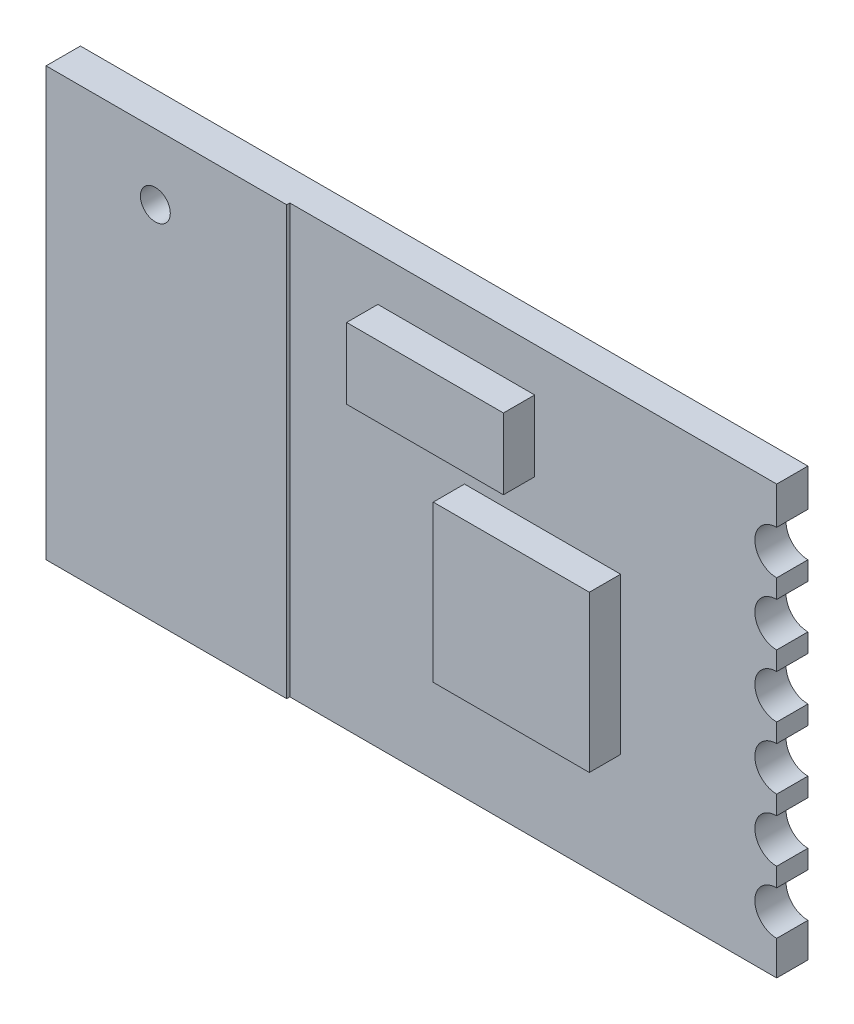
from build123d import *

# Parameters (mm, degrees)
BOSS_EXTRUDE1_DEPTH = 1
SKETCH2_W           = 7.706049631
SKETCH2_H           = 13.7
BOSS_EXTRUDE2_DEPTH = 0.1
SKETCH3_R           = 0.478791287
CUT_EXTRUDE1_DEPTH  = 2.1
SKETCH4_W           = 5
SKETCH4_H           = 5
BOSS_EXTRUDE3_DEPTH = 1
SKETCH6_W           = 5.021657736
SKETCH6_H           = 2.270064456
BOSS_EXTRUDE5_DEPTH = 1


with BuildPart() as part:
    # Sketch1 → Boss-Extrude1 (new body)
    with BuildSketch(Plane.XY):
        with BuildLine():
            Line((13.817814776, 5.306721311), (13.817814776, 4.706721311))
            ThreePointArc((13.817814776, 4.706721311), (13.117814776, 4.006721311), (13.817814776, 3.306721311))
            Line((13.817814776, 3.306721311), (13.817814776, 2.706721311))
            ThreePointArc((13.817814776, 2.706721311), (13.117814776, 2.006721311), (13.817814776, 1.306721311))
            Line((13.817814776, 1.306721311), (13.817814776, 0.706721311))
            ThreePointArc((13.817814776, 0.706721311), (13.117814776, 0.006721311), (13.817814776, -0.693278689))
            Line((13.817814776, -0.693278689), (13.817814776, -1.293278689))
            ThreePointArc((13.817814776, -1.293278689), (13.117814776, -1.993278689), (13.817814776, -2.693278689))
            Line((13.817814776, -2.693278689), (13.817814776, -3.293278689))
            ThreePointArc((13.817814776, -3.293278689), (13.117814776, -3.993278689), (13.817814776, -4.693278689))
            Line((13.817814776, -4.693278689), (13.817814776, -5.793278689))
            Line((13.817814776, -5.793278689), (-9.482185224, -5.793278689))
            Line((-9.482185224, -5.793278689), (-9.482185224, 7.906721311))
            Line((-9.482185224, 7.906721311), (13.817814776, 7.906721311))
            Line((13.817814776, 7.906721311), (13.817814776, 6.706721311))
            ThreePointArc((13.817814776, 6.706721311), (13.117814776, 6.006721311), (13.817814776, 5.306721311))
        make_face()
    extrude(amount=BOSS_EXTRUDE1_DEPTH)

    # Sketch2 → Boss-Extrude2 (add)
    with BuildSketch(Plane.XY.offset(1)):
        with Locations((-5.629160408, 1.056721311)):
            Rectangle(SKETCH2_W, SKETCH2_H)
    extrude(amount=BOSS_EXTRUDE2_DEPTH)

    # Sketch3 → Cut-Extrude1 (cut)
    with BuildSketch(Plane.XY.offset(1.1)):
        with Locations((-5.982185224, 5.806721311)):
            Circle(SKETCH3_R)
    extrude(amount=-CUT_EXTRUDE1_DEPTH, mode=Mode.SUBTRACT)

    # Sketch4 → Boss-Extrude3 (add)
    with BuildSketch(Plane.XY.offset(1)):
        with Locations((6.317814776, 0.406721311)):
            Rectangle(SKETCH4_W, SKETCH4_H)
    extrude(amount=BOSS_EXTRUDE3_DEPTH)

    # Sketch6 → Boss-Extrude5 (add)
    with BuildSketch(Plane.XY.offset(1)):
        with Locations((3.555076388, 5.367550784)):
            Rectangle(SKETCH6_W, SKETCH6_H)
    extrude(amount=BOSS_EXTRUDE5_DEPTH)


solid = part.part
